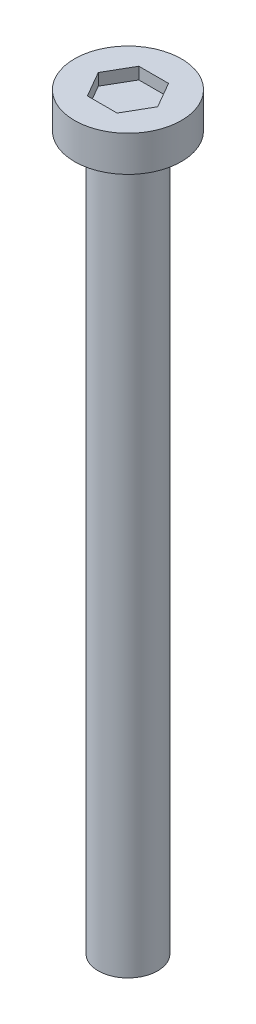
from build123d import *

# Parameters (mm, degrees)
SKETCH1_R           = 1.25
BOSS_EXTRUDE1_DEPTH = 30
SKETCH4_R           = 2.25
BOSS_EXTRUDE2_DEPTH = 1.5
CUT_EXTRUDE1_DEPTH  = 0.5


with BuildPart() as part:
    # Sketch1 → Boss-Extrude1 (new body)
    with BuildSketch(Plane(origin=(0, 0, 0), x_dir=(1, 0, 0), z_dir=(0, 1, 0))):
        Circle(SKETCH1_R)
    extrude(amount=BOSS_EXTRUDE1_DEPTH)

    # Sketch4 → Boss-Extrude2 (add)
    with BuildSketch(Plane(origin=(0, 30, 0), x_dir=(1, 0, 0), z_dir=(0, 1, 0))):
        Circle(SKETCH4_R)
    extrude(amount=BOSS_EXTRUDE2_DEPTH)

    # Sketch5 → Cut-Extrude1 (cut)
    with BuildSketch(Plane(origin=(0, 31.5, 0), x_dir=(1, 0, 0), z_dir=(0, 1, 0))):
        Polygon((1.25, 0), (0.625, 1.082531755), (-0.625, 1.082531755), (-1.25, 0), (-0.625, -1.082531755), (0.625, -1.082531755), align=None)
    extrude(amount=-CUT_EXTRUDE1_DEPTH, mode=Mode.SUBTRACT)


solid = part.part
